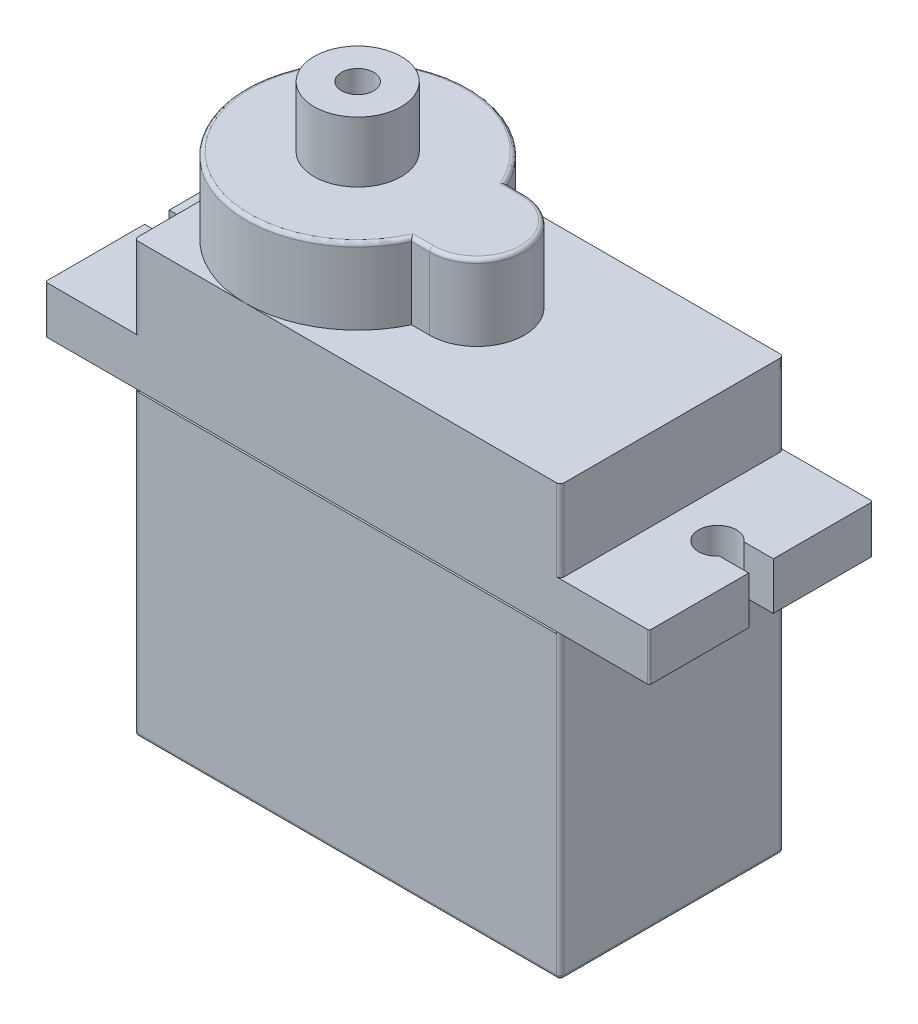
from build123d import *

# Parameters (mm, degrees)
SKETCH1_W           = 22.5
SKETCH1_H           = 22.7
BOSS_EXTRUDE1_DEPTH = 11.8
SKETCH2_W           = 11.8
SKETCH2_H           = 2.5
BOSS_EXTRUDE2_DEPTH = 4.7
SKETCH3_W           = 11.8
SKETCH3_H           = 2.5
BOSS_EXTRUDE3_DEPTH = 4.7
CUT_EXTRUDE1_DEPTH  = 4.7
BOSS_EXTRUDE4_DEPTH = 4
SKETCH6_R           = 2.3
SKETCH6_R_2         = 0.85
BOSS_EXTRUDE5_DEPTH = 3.2
CUT_EXTRUDE2_DEPTH  = 0.1
FILLET1_R           = 0.2
SKETCH8_W           = 22.1
SKETCH8_H           = 0.1
CUT_EXTRUDE3_DEPTH  = 0.1
SKETCH9_W           = 22.1
SKETCH9_H           = 0.1
CUT_EXTRUDE4_DEPTH  = 0.1
FILLET2_R           = 0.1


with BuildPart() as part:
    # Sketch1 → Boss-Extrude1 (new body)
    with BuildSketch(Plane.XY):
        with Locations((11.25, 11.35)):
            Rectangle(SKETCH1_W, SKETCH1_H)
    extrude(amount=BOSS_EXTRUDE1_DEPTH)

    # Sketch2 → Boss-Extrude2 (add)
    with BuildSketch(Plane(origin=(22.5, 0, 0), x_dir=(0, 0, -1), z_dir=(1, 0, 0))):
        with Locations((-5.9, 17.15)):
            Rectangle(SKETCH2_W, SKETCH2_H)
    extrude(amount=BOSS_EXTRUDE2_DEPTH)

    # Sketch3 → Boss-Extrude3 (add)
    with BuildSketch(Plane.ZY):
        with Locations((5.9, 17.15)):
            Rectangle(SKETCH3_W, SKETCH3_H)
    extrude(amount=BOSS_EXTRUDE3_DEPTH)

    # Sketch4 → Cut-Extrude1 (cut)
    with BuildSketch(Plane(origin=(0, 18.4, 0), x_dir=(1, 0, 0), z_dir=(0, 1, 0))):
        with BuildLine():
            Line((27.2, -5.25), (25.659934208, -5.25))
            ThreePointArc((25.659934208, -5.25), (23.9, -5.9), (25.659934208, -6.55))
            Line((25.659934208, -6.55), (27.2, -6.55))
            Line((27.2, -6.55), (27.2, -5.25))
        make_face()
        with BuildLine():
            Line((-4.7, -5.25), (-3.159934208, -5.25))
            ThreePointArc((-3.159934208, -5.25), (-1.4, -5.9), (-3.159934208, -6.55))
            Line((-3.159934208, -6.55), (-4.7, -6.55))
            Line((-4.7, -6.55), (-4.7, -5.25))
        make_face()
    extrude(amount=-CUT_EXTRUDE1_DEPTH, mode=Mode.SUBTRACT)

    # Sketch5 → Boss-Extrude4 (add)
    with BuildSketch(Plane(origin=(0, 22.7, 0), x_dir=(1, 0, 0), z_dir=(0, 1, 0))):
        with BuildLine():
            Line((12.2, -3.4), (11.244155686, -3.4))
            ThreePointArc((11.244155686, -3.4), (0, -5.9), (11.244155686, -8.4))
            Line((11.244155686, -8.4), (12.2, -8.4))
            ThreePointArc((12.2, -8.4), (14.7, -5.9), (12.2, -3.4))
        make_face()
    extrude(amount=BOSS_EXTRUDE4_DEPTH)

    # Sketch6 → Boss-Extrude5 (add)
    with BuildSketch(Plane(origin=(0, 26.7, 0), x_dir=(1, 0, 0), z_dir=(0, 1, 0))):
        with Locations((5.9, -5.9)):
            Circle(SKETCH6_R)
        with Locations((5.9, -5.9)):
            Circle(SKETCH6_R_2, mode=Mode.SUBTRACT)
    extrude(amount=BOSS_EXTRUDE5_DEPTH)

    # Sketch7 → Cut-Extrude2 (cut)
    with BuildSketch(Plane(origin=(0, 0, 0), x_dir=(-1, 0, 0), z_dir=(0, 0, -1))):
        with BuildLine():
            Line((-17.532795325, 8.733140918), (-17.236921928, 8.910524733))
            add(Edge.make_bspline(
                [(-17.236921928, 8.910524733), (-17.209403691, 8.864460348), (-17.15667981, 8.776202764), (-17.068728451, 8.656944723), (-16.97759554, 8.555582566), (-16.882606206, 8.472705959), (-16.784340258, 8.407457072), (-16.682156204, 8.36125484), (-16.576398394, 8.332438865), (-16.504424572, 8.328938779), (-16.468492441, 8.327191399)],
                knots=[0, 0, 0, 0, 0.000160901, 0.00030828, 0.000443778, 0.00056903, 0.000685513, 0.000796284, 0.00090427, 0.001011928, 0.001011928, 0.001011928, 0.001011928], degree=3))
            add(Edge.make_bspline(
                [(-16.468492441, 8.327191399), (-16.43780558, 8.328046072), (-16.376968807, 8.329740462), (-16.287406564, 8.346021264), (-16.200424762, 8.371033393), (-16.117816124, 8.406854324), (-16.04072051, 8.45019281), (-15.973113814, 8.502538988), (-15.914667701, 8.561145193), (-15.866858587, 8.626527848), (-15.830178551, 8.696844997), (-15.801986483, 8.769020948), (-15.786341409, 8.844189516), (-15.783984656, 8.894799979), (-15.782795325, 8.920340438)],
                knots=[0, 0, 0, 0, 9.1978e-05, 0.000182347, 0.000272202, 0.000362975, 0.000451852, 0.000536835, 0.000618639, 0.000699414, 0.000778765, 0.000855983, 0.0009312, 0.001007828, 0.001007828, 0.001007828, 0.001007828], degree=3))
            add(Edge.make_bspline(
                [(-15.782795325, 8.920340438), (-15.784269636, 8.949481287), (-15.787266694, 9.008720376), (-15.812598174, 9.096120029), (-15.852447421, 9.182612599), (-15.889210065, 9.236113865), (-15.908296127, 9.263890117)],
                knots=[0, 0, 0, 0, 8.7281e-05, 0.000177429, 0.000270909, 0.000371844, 0.000371844, 0.000371844, 0.000371844], degree=3))
            add(Edge.make_bspline(
                [(-15.908296127, 9.263890117), (-15.923966741, 9.283936941), (-15.956865235, 9.326022739), (-16.013422748, 9.388667975), (-16.079788862, 9.453286394), (-16.153692417, 9.522345451), (-16.237825506, 9.592633247), (-16.32955302, 9.667501525), (-16.431216879, 9.744103102), (-16.502516376, 9.795475668), (-16.539305742, 9.821983066)],
                knots=[0, 0, 0, 0, 7.6319e-05, 0.000160223, 0.000252933, 0.000354147, 0.000463581, 0.000581729, 0.000709336, 0.000845369, 0.000845369, 0.000845369, 0.000845369], degree=3))
            add(Edge.make_bspline(
                [(-16.539305742, 9.821983066), (-16.576129738, 9.848211653), (-16.646534415, 9.898358716), (-16.744992997, 9.972783), (-16.83303746, 10.040826869), (-16.910276477, 10.103130881), (-16.976676073, 10.159703486), (-17.032759484, 10.210001425), (-17.077098042, 10.255384986), (-17.101753622, 10.284826328), (-17.11282337, 10.298044765)],
                knots=[0, 0, 0, 0, 0.000135623, 0.000259301, 0.000370234, 0.000469439, 0.00055697, 0.000631911, 0.000695377, 0.00074709, 0.00074709, 0.00074709, 0.00074709], degree=3))
            add(Edge.make_bspline(
                [(-17.11282337, 10.298044765), (-17.128295915, 10.318645801), (-17.158724752, 10.359160505), (-17.198890758, 10.422485363), (-17.23302992, 10.487308628), (-17.259792252, 10.553804493), (-17.282328471, 10.621039422), (-17.297486402, 10.689890668), (-17.306977799, 10.760049286), (-17.307949786, 10.807262787), (-17.308436351, 10.830897329)],
                knots=[0, 0, 0, 0, 7.727e-05, 0.000151962, 0.000224716, 0.000296717, 0.00036678, 0.0004372, 0.000507902, 0.000578771, 0.000578771, 0.000578771, 0.000578771], degree=3))
            add(Edge.make_bspline(
                [(-17.308436351, 10.830897329), (-17.307131142, 10.867927103), (-17.304548622, 10.941195167), (-17.282708105, 11.048225997), (-17.248235211, 11.150412415), (-17.199940323, 11.246742748), (-17.13768297, 11.334708729), (-17.065636996, 11.415322216), (-16.97982551, 11.483090798), (-16.885672886, 11.542302857), (-16.782616514, 11.588648782), (-16.674625611, 11.623609762), (-16.561528539, 11.64341902), (-16.484925404, 11.646261785), (-16.446056543, 11.64770422)],
                knots=[0, 0, 0, 0, 0.000110999, 0.000219625, 0.000326272, 0.00043382, 0.000541574, 0.000648775, 0.000756959, 0.000868438, 0.000981703, 0.00109501, 0.001208203, 0.0013248, 0.0013248, 0.0013248, 0.0013248], degree=3))
            add(Edge.make_bspline(
                [(-16.446056543, 11.64770422), (-16.404812443, 11.646281668), (-16.322791091, 11.643452667), (-16.202141876, 11.618855136), (-16.085981159, 11.578154464), (-15.992537894, 11.531965806), (-15.919405133, 11.48583439), (-15.8636324, 11.443814566), (-15.807114949, 11.395439457), (-15.749396895, 11.340580211), (-15.691456235, 11.27873346), (-15.632432783, 11.210322771), (-15.572188514, 11.135766215), (-15.533432654, 11.082541715), (-15.513564556, 11.055256303)],
                knots=[0, 0, 0, 0, 0.000123638, 0.000245877, 0.000367608, 0.000492088, 0.000557638, 0.000626769, 0.000701372, 0.00078072, 0.000865532, 0.000955497, 0.001051745, 0.001152989, 0.001152989, 0.001152989, 0.001152989], degree=3))
            Line((-15.513564556, 11.055256303), (-15.797518883, 10.840011912))
            add(Edge.make_bspline(
                [(-15.797518883, 10.840011912), (-15.814664815, 10.862100602), (-15.847683873, 10.904638256), (-15.897813359, 10.964209571), (-15.945062007, 11.018626051), (-15.991612407, 11.065891179), (-16.035006039, 11.108593312), (-16.077123081, 11.145153069), (-16.117357432, 11.175928664), (-16.168074343, 11.208772224), (-16.231792061, 11.241328728), (-16.311776597, 11.268877806), (-16.395362872, 11.285432868), (-16.452292504, 11.287621755), (-16.481112633, 11.288729861)],
                knots=[0, 0, 0, 0, 8.3877e-05, 0.000161528, 0.000233552, 0.000299993, 0.000360485, 0.000416152, 0.000467195, 0.000512312, 0.000597287, 0.000681099, 0.000765389, 0.000851809, 0.000851809, 0.000851809, 0.000851809], degree=3))
            add(Edge.make_bspline(
                [(-16.481112633, 11.288729861), (-16.517269155, 11.287518161), (-16.586993603, 11.285181512), (-16.685983839, 11.259661526), (-16.775077764, 11.219479666), (-16.851630329, 11.163164688), (-16.915367306, 11.096443695), (-16.961472765, 11.01966484), (-16.989222929, 10.934882437), (-16.992609209, 10.875740781), (-16.994333787, 10.845620886)],
                knots=[0, 0, 0, 0, 0.000108248, 0.000208746, 0.00030443, 0.000399793, 0.000492054, 0.00057947, 0.000666386, 0.000756591, 0.000756591, 0.000756591, 0.000756591], degree=3))
            add(Edge.make_bspline(
                [(-16.994333787, 10.845620886), (-16.99394066, 10.826869408), (-16.993153764, 10.789335788), (-16.982178966, 10.733884366), (-16.968079637, 10.678573027), (-16.945737006, 10.623650444), (-16.914891702, 10.568156085), (-16.874386526, 10.511134348), (-16.823373214, 10.452082639), (-16.784296202, 10.413675265), (-16.763664716, 10.393397329)],
                knots=[0, 0, 0, 0, 5.616e-05, 0.000112411, 0.000169046, 0.000227244, 0.000289691, 0.000359134, 0.000436702, 0.000523463, 0.000523463, 0.000523463, 0.000523463], degree=3))
            add(Edge.make_bspline(
                [(-16.763664716, 10.393397329), (-16.756003344, 10.386560303), (-16.737801677, 10.370317095), (-16.704525751, 10.343724814), (-16.660582953, 10.310922042), (-16.607120752, 10.270334725), (-16.54315339, 10.223253263), (-16.468673834, 10.170279651), (-16.384512301, 10.109694192), (-16.324790385, 10.067336651), (-16.293211992, 10.044939797)],
                knots=[0, 0, 0, 0, 3.0802e-05, 7.3177e-05, 0.000127725, 0.000195314, 0.000274544, 0.000365991, 0.000469501, 0.000585644, 0.000585644, 0.000585644, 0.000585644], degree=3))
            add(Edge.make_bspline(
                [(-16.293211992, 10.044939797), (-16.255226079, 10.017298437), (-16.181671622, 9.963774775), (-16.077014042, 9.883359095), (-15.982120234, 9.804711327), (-15.896657031, 9.72833372), (-15.819780122, 9.654805627), (-15.752342402, 9.583242446), (-15.693656721, 9.514156874), (-15.630477503, 9.425584298), (-15.565919683, 9.316803214), (-15.510478176, 9.183524975), (-15.475519828, 9.049728655), (-15.470948313, 8.959801818), (-15.468692761, 8.915432585)],
                knots=[0, 0, 0, 0, 0.000140932, 0.000272896, 0.000395881, 0.000510584, 0.000616697, 0.000714904, 0.000805482, 0.000888372, 0.001041088, 0.001183793, 0.001320341, 0.001453327, 0.001453327, 0.001453327, 0.001453327], degree=3))
            add(Edge.make_bspline(
                [(-15.468692761, 8.915432585), (-15.469349899, 8.88405422), (-15.470651414, 8.821906836), (-15.485612328, 8.73065176), (-15.507531993, 8.64202089), (-15.540569227, 8.557109777), (-15.580892386, 8.474365015), (-15.632058633, 8.395957114), (-15.691366318, 8.320150716), (-15.759400083, 8.248967224), (-15.833845985, 8.183621028), (-15.91252968, 8.125491967), (-15.995579953, 8.077023644), (-16.08254627, 8.037472801), (-16.173448606, 8.006539284), (-16.26825639, 7.984126415), (-16.367125901, 7.970370704), (-16.434326383, 7.968942942), (-16.468492441, 7.96821704)],
                knots=[0, 0, 0, 0, 9.4044e-05, 0.000186263, 0.000276729, 0.000367488, 0.000459046, 0.000552398, 0.000647774, 0.000747454, 0.000847311, 0.000944634, 0.001040472, 0.001135227, 0.001230788, 0.001328063, 0.00142712, 0.00152957, 0.00152957, 0.00152957, 0.00152957], degree=3))
            add(Edge.make_bspline(
                [(-16.468492441, 7.96821704), (-16.494927784, 7.968728222), (-16.547465544, 7.969744147), (-16.625175026, 7.978725428), (-16.701314615, 7.991432531), (-16.774928897, 8.011606601), (-16.846966308, 8.036083578), (-16.917113543, 8.066221911), (-16.985404597, 8.102339112), (-17.05222218, 8.143634137), (-17.117396354, 8.191691881), (-17.180315822, 8.247665378), (-17.243045008, 8.310010883), (-17.303732404, 8.380421446), (-17.363605548, 8.457759529), (-17.421483958, 8.542748713), (-17.478565676, 8.634926066), (-17.514381143, 8.699791152), (-17.532795325, 8.733140918)],
                knots=[0, 0, 0, 0, 7.9276e-05, 0.000157554, 0.000234438, 0.000310629, 0.000386236, 0.000462555, 0.000539392, 0.000617798, 0.000698008, 0.000781971, 0.000870217, 0.00096315, 0.001060616, 0.001163492, 0.001271478, 0.00138575, 0.00138575, 0.00138575, 0.00138575], degree=3))
        make_face()
        with BuildLine():
            Line((-11.475103018, 10.960604861), (-11.744333787, 10.705396527))
            add(Edge.make_bspline(
                [(-11.744333787, 10.705396527), (-11.793052675, 10.75122739), (-11.889328721, 10.841796253), (-12.046288964, 10.959307248), (-12.210052598, 11.059973349), (-12.379765095, 11.141879585), (-12.551223649, 11.207232346), (-12.722152425, 11.253760486), (-12.890798127, 11.283433023), (-13.002965345, 11.286981393), (-13.05823603, 11.288729861)],
                knots=[0, 0, 0, 0, 0.000200536, 0.000396289, 0.000586999, 0.000776397, 0.000960787, 0.001136655, 0.001307246, 0.001472961, 0.001472961, 0.001472961, 0.001472961], degree=3))
            add(Edge.make_bspline(
                [(-13.05823603, 11.288729861), (-13.09215073, 11.288316255), (-13.159892171, 11.287490116), (-13.260514115, 11.2769459), (-13.360080752, 11.261781036), (-13.458404127, 11.239839159), (-13.555675413, 11.212030099), (-13.651556305, 11.177244636), (-13.74622566, 11.136689392), (-13.838791741, 11.089826918), (-13.928532245, 11.038347072), (-14.01328908, 10.981298531), (-14.093602479, 10.920509741), (-14.167962905, 10.854458762), (-14.236798091, 10.783743896), (-14.301746463, 10.70968059), (-14.360523759, 10.630245372), (-14.413614924, 10.546899746), (-14.460976542, 10.461107556), (-14.502785196, 10.373694567), (-14.537882284, 10.284950712), (-14.565651739, 10.194764635), (-14.588562393, 10.103834045), (-14.60468, 10.011529324), (-14.613766723, 9.917751639), (-14.615338503, 9.85495438), (-14.616128659, 9.823385309)],
                knots=[0, 0, 0, 0, 0.000101701, 0.000203139, 0.000303193, 0.000403728, 0.000505139, 0.000606491, 0.000709509, 0.000813922, 0.000917583, 0.001019673, 0.001120217, 0.001219549, 0.001317716, 0.001416124, 0.001514842, 0.00161384, 0.001712379, 0.001808658, 0.001904353, 0.001998376, 0.002091562, 0.002185504, 0.002279198, 0.002373914, 0.002373914, 0.002373914, 0.002373914], degree=3))
            add(Edge.make_bspline(
                [(-14.616128659, 9.823385309), (-14.61537294, 9.791114492), (-14.613863567, 9.726660979), (-14.604203248, 9.630466906), (-14.586275007, 9.535701504), (-14.562307299, 9.442053371), (-14.532326483, 9.349362123), (-14.494953817, 9.258029613), (-14.450688216, 9.168059222), (-14.399451664, 9.080261605), (-14.343265461, 8.994738581), (-14.28032238, 8.91417906), (-14.213461796, 8.837510282), (-14.140247897, 8.766434519), (-14.063028354, 8.699050622), (-13.979496078, 8.6372151), (-13.891293618, 8.579736877), (-13.798286406, 8.527340358), (-13.701483623, 8.480531822), (-13.60222687, 8.438907926), (-13.500199055, 8.404628589), (-13.395936365, 8.376690485), (-13.289563093, 8.353790187), (-13.180539291, 8.339057707), (-13.069666582, 8.328366876), (-12.99492795, 8.327585206), (-12.957274492, 8.327191399)],
                knots=[0, 0, 0, 0, 9.6818e-05, 0.000193372, 0.000289633, 0.000385881, 0.000483216, 0.000581645, 0.00068167, 0.000783767, 0.00088644, 0.000988395, 0.001090231, 0.001191373, 0.001294266, 0.001397472, 0.001502873, 0.001609927, 0.001717482, 0.001825293, 0.001932604, 0.002040093, 0.002149, 0.002258763, 0.002369974, 0.002482889, 0.002482889, 0.002482889, 0.002482889], degree=3))
            add(Edge.make_bspline(
                [(-12.957274492, 8.327191399), (-12.911896145, 8.328139975), (-12.822788387, 8.330002659), (-12.691801945, 8.344502949), (-12.565998874, 8.367149742), (-12.445732671, 8.400315639), (-12.33086365, 8.442619314), (-12.220970709, 8.4936147), (-12.11691905, 8.555257759), (-12.018395877, 8.624831627), (-11.927638691, 8.702346459), (-11.845784567, 8.785990914), (-11.774139078, 8.875358981), (-11.711634378, 8.969924296), (-11.659925724, 9.070469601), (-11.617482929, 9.176502164), (-11.584949637, 9.288069676), (-11.571594663, 9.365161307), (-11.564846607, 9.404114476)],
                knots=[0, 0, 0, 0, 0.000136106, 0.000267267, 0.000394882, 0.00051922, 0.000641, 0.000761758, 0.000882124, 0.001003321, 0.001123172, 0.001239687, 0.001353892, 0.00146629, 0.00157918, 0.001692449, 0.001808499, 0.001927028, 0.001927028, 0.001927028, 0.001927028], degree=3))
            Line((-11.564846607, 9.404114476), (-12.731513274, 9.404114476))
            Line((-12.731513274, 9.404114476), (-12.731513274, 9.763088835))
            Line((-12.731513274, 9.763088835), (-11.250744043, 9.763088835))
            add(Edge.make_bspline(
                [(-11.250744043, 9.763088835), (-11.252449892, 9.696181346), (-11.255788545, 9.565231304), (-11.279207461, 9.374261034), (-11.317023973, 9.19388934), (-11.368684285, 9.023926269), (-11.435559565, 8.864612676), (-11.516932094, 8.71578681), (-11.614104215, 8.578410129), (-11.723614656, 8.451361125), (-11.846514614, 8.338031913), (-11.979483234, 8.238425975), (-12.122740202, 8.15452336), (-12.27615001, 8.086262697), (-12.439210443, 8.032988703), (-12.612298823, 7.995217126), (-12.795180424, 7.972587162), (-12.920517101, 7.969695783), (-12.984618242, 7.96821704)],
                knots=[0, 0, 0, 0, 0.000200697, 0.000392801, 0.000576238, 0.000752994, 0.000924878, 0.001093697, 0.001260784, 0.001428776, 0.001595974, 0.001761299, 0.001926279, 0.002092931, 0.002264096, 0.002439994, 0.002623661, 0.002815923, 0.002815923, 0.002815923, 0.002815923], degree=3))
            add(Edge.make_bspline(
                [(-12.984618242, 7.96821704), (-13.024128377, 7.968786161), (-13.102055098, 7.969908652), (-13.217146026, 7.977885999), (-13.329063647, 7.990166576), (-13.437791656, 8.008711699), (-13.543729998, 8.031426353), (-13.646349583, 8.060513072), (-13.746041325, 8.094181771), (-13.84295931, 8.132477445), (-13.936223857, 8.176849102), (-14.026250374, 8.226158741), (-14.1135365, 8.280152102), (-14.197487665, 8.339762948), (-14.278541286, 8.404545408), (-14.35617473, 8.474629327), (-14.430822608, 8.549800446), (-14.477583072, 8.603179456), (-14.501144684, 8.630076015)],
                knots=[0, 0, 0, 0, 0.000118523, 0.000233765, 0.000345956, 0.000456148, 0.000564516, 0.000670839, 0.000775933, 0.000880089, 0.000983271, 0.001085557, 0.001187895, 0.001290998, 0.001394253, 0.001499002, 0.001604602, 0.001711853, 0.001711853, 0.001711853, 0.001711853], degree=3))
            add(Edge.make_bspline(
                [(-14.501144684, 8.630076015), (-14.535330616, 8.672746668), (-14.603135029, 8.757379685), (-14.690413185, 8.892979629), (-14.764814588, 9.033381489), (-14.82518241, 9.178976118), (-14.872320497, 9.329627331), (-14.906126749, 9.485142622), (-14.925934039, 9.645722252), (-14.928787576, 9.754387517), (-14.930231223, 9.809362874)],
                knots=[0, 0, 0, 0, 0.00016394, 0.000325158, 0.000482912, 0.000640071, 0.000797293, 0.000955853, 0.00111691, 0.001281823, 0.001281823, 0.001281823, 0.001281823], degree=3))
            add(Edge.make_bspline(
                [(-14.930231223, 9.809362874), (-14.929698985, 9.850529126), (-14.928641273, 9.932338434), (-14.915815757, 10.053795741), (-14.897414339, 10.173096433), (-14.870367284, 10.29014299), (-14.836271019, 10.405013581), (-14.793717533, 10.517761545), (-14.744172637, 10.628453417), (-14.686587141, 10.736327285), (-14.622502682, 10.839951698), (-14.552952461, 10.938909501), (-14.476948861, 11.031398566), (-14.395733062, 11.118590214), (-14.308336071, 11.199389061), (-14.215576648, 11.274543172), (-14.117383305, 11.344153358), (-14.013447125, 11.407123192), (-13.90531944, 11.463686813), (-13.793259439, 11.513276025), (-13.677301328, 11.55425934), (-13.55831385, 11.58903312), (-13.43539635, 11.61474826), (-13.309440813, 11.633397006), (-13.179790701, 11.646157605), (-13.092154672, 11.647183861), (-13.047719203, 11.64770422)],
                knots=[0, 0, 0, 0, 0.000123447, 0.000245326, 0.00036601, 0.000485407, 0.000605413, 0.000725221, 0.000846669, 0.000968994, 0.001091771, 0.00121199, 0.001331568, 0.001450618, 0.001569191, 0.001688326, 0.001808545, 0.001929991, 0.002052609, 0.002174413, 0.002297271, 0.002421315, 0.002546037, 0.002673651, 0.002803207, 0.002936466, 0.002936466, 0.002936466, 0.002936466], degree=3))
            add(Edge.make_bspline(
                [(-13.047719203, 11.64770422), (-13.01148096, 11.647124728), (-12.939624781, 11.645975664), (-12.832699049, 11.638011016), (-12.727426034, 11.625387135), (-12.623649644, 11.608160348), (-12.521723278, 11.584696658), (-12.421356573, 11.556618373), (-12.322404036, 11.52392655), (-12.225175787, 11.484937704), (-12.129018071, 11.440684079), (-12.033396231, 11.390870657), (-11.938636985, 11.334645652), (-11.844576003, 11.271842117), (-11.750620145, 11.203538699), (-11.658255503, 11.127781875), (-11.565252559, 11.047559119), (-11.505450745, 10.989876935), (-11.475103018, 10.960604861)],
                knots=[0, 0, 0, 0, 0.00010871, 0.000215559, 0.000321482, 0.000426718, 0.00053098, 0.000635089, 0.000739295, 0.000843451, 0.000949174, 0.001056739, 0.001166761, 0.001279546, 0.001395941, 0.001515076, 0.00163782, 0.001764288, 0.001764288, 0.001764288, 0.001764288], degree=3))
        make_face()
        with BuildLine():
            Line((-8.73792353, 7.96821704), (-8.988925133, 8.142796367))
            Line((-8.988925133, 8.142796367), (-8.015768082, 9.565372489))
            add(Edge.make_bspline(
                [(-8.015768082, 9.565372489), (-8.077858817, 9.557779426), (-8.200118937, 9.542828261), (-8.323256039, 9.540081606), (-8.383857024, 9.538729861)],
                knots=[0, 0, 0, 0, 0.000187529, 0.000369255, 0.000369255, 0.000369255, 0.000369255], degree=3))
            add(Edge.make_bspline(
                [(-8.383857024, 9.538729861), (-8.420599072, 9.539670937), (-8.492720499, 9.541518188), (-8.598752151, 9.556159996), (-8.700637712, 9.578710124), (-8.798107068, 9.612358879), (-8.891526573, 9.654177088), (-8.980692286, 9.706034102), (-9.065484176, 9.767040393), (-9.144991586, 9.836873385), (-9.217303325, 9.913551437), (-9.281726623, 9.99470708), (-9.335267755, 10.081283051), (-9.37974434, 10.17151327), (-9.413474794, 10.266694621), (-9.438037332, 10.365744021), (-9.453159686, 10.469355663), (-9.454958781, 10.539880794), (-9.455872248, 10.575688995)],
                knots=[0, 0, 0, 0, 0.000110185, 0.000216284, 0.000320547, 0.000422759, 0.000525058, 0.000627155, 0.000731643, 0.000837964, 0.0009441, 0.00104747, 0.001148247, 0.001248901, 0.001348697, 0.001450555, 0.001554666, 0.00166205, 0.00166205, 0.00166205, 0.00166205], degree=3))
            add(Edge.make_bspline(
                [(-9.455872248, 10.575688995), (-9.454137814, 10.624657648), (-9.45073347, 10.72077318), (-9.423334953, 10.861206949), (-9.378274613, 10.993993492), (-9.315446237, 11.118783686), (-9.236311515, 11.233782425), (-9.141202925, 11.337391035), (-9.030698961, 11.428135888), (-8.907316942, 11.506139966), (-8.773963921, 11.568874963), (-8.634295263, 11.615114264), (-8.489381143, 11.642313011), (-8.391213473, 11.645898873), (-8.341789716, 11.64770422)],
                knots=[0, 0, 0, 0, 0.000146818, 0.000288173, 0.000427413, 0.000566316, 0.000705952, 0.000844895, 0.000986821, 0.001133677, 0.001281714, 0.001427825, 0.001574003, 0.00172222, 0.00172222, 0.00172222, 0.00172222], degree=3))
            add(Edge.make_bspline(
                [(-8.341789716, 11.64770422), (-8.293301297, 11.645874057), (-8.19749275, 11.642257827), (-8.056603743, 11.615773858), (-7.921662726, 11.571137185), (-7.79341774, 11.509452621), (-7.674678327, 11.432131714), (-7.567902516, 11.33999719), (-7.475526977, 11.232991663), (-7.397703096, 11.113703173), (-7.335233056, 10.985536191), (-7.290160773, 10.851752269), (-7.262415134, 10.713313548), (-7.258918807, 10.619519074), (-7.2571543, 10.572183386)],
                knots=[0, 0, 0, 0, 0.000145418, 0.000287333, 0.000428343, 0.000570713, 0.000713061, 0.00085223, 0.000992387, 0.001135706, 0.001278381, 0.001418948, 0.001558239, 0.001700158, 0.001700158, 0.001700158, 0.001700158], degree=3))
            add(Edge.make_bspline(
                [(-7.2571543, 10.572183386), (-7.258332709, 10.535439619), (-7.260722816, 10.460914079), (-7.277459123, 10.347683736), (-7.305879309, 10.232232506), (-7.338131007, 10.13451091), (-7.369263175, 10.053802461), (-7.398564307, 9.990050881), (-7.43107646, 9.922949617), (-7.468995226, 9.853202279), (-7.509757522, 9.779919745), (-7.555816799, 9.703837029), (-7.606122371, 9.624852036), (-7.64195209, 9.571604948), (-7.660299332, 9.544338835)],
                knots=[0, 0, 0, 0, 0.000110219, 0.000223552, 0.000342587, 0.000466527, 0.000532018, 0.000601997, 0.000676938, 0.00075567, 0.000840114, 0.000928491, 0.001022434, 0.001121023, 0.001121023, 0.001121023, 0.001121023], degree=3))
            Line((-7.660299332, 9.544338835), (-8.73792353, 7.96821704))
        make_face()
        with BuildLine():
            add(Edge.make_bspline(
                [(-8.325663915, 9.89770422), (-8.297829901, 9.898464603), (-8.243646538, 9.899944812), (-8.164269239, 9.908954054), (-8.089345035, 9.92492804), (-8.018673786, 9.947847752), (-7.951546884, 9.975504421), (-7.889030556, 10.010716407), (-7.831072481, 10.052733042), (-7.777284554, 10.099943058), (-7.729520554, 10.152393641), (-7.686977523, 10.207290748), (-7.650816956, 10.264875358), (-7.622253679, 10.32586862), (-7.598769103, 10.388785829), (-7.582551091, 10.454640184), (-7.573566758, 10.523088585), (-7.572035183, 10.569587243), (-7.571256864, 10.59321704)],
                knots=[0, 0, 0, 0, 8.3507e-05, 0.00016256, 0.000239294, 0.000312908, 0.000385178, 0.000456751, 0.000527578, 0.000599603, 0.000671055, 0.000740051, 0.000807755, 0.000874553, 0.000941763, 0.001008931, 0.001077548, 0.001148448, 0.001148448, 0.001148448, 0.001148448], degree=3))
            add(Edge.make_bspline(
                [(-7.571256864, 10.59321704), (-7.571926533, 10.616856705), (-7.573246198, 10.663441565), (-7.583833498, 10.731991305), (-7.602458721, 10.797684566), (-7.627449206, 10.860880996), (-7.660369444, 10.921061368), (-7.699872929, 10.97898124), (-7.746805379, 11.034273367), (-7.800807945, 11.085637351), (-7.859042498, 11.13298525), (-7.921102998, 11.174771326), (-7.986477914, 11.209792523), (-8.054768404, 11.238691493), (-8.126116753, 11.261243268), (-8.200480741, 11.277460633), (-8.278236147, 11.286432387), (-8.331017433, 11.287954282), (-8.357915518, 11.288729861)],
                knots=[0, 0, 0, 0, 7.09e-05, 0.000139717, 0.000207422, 0.000275384, 0.000343146, 0.000412766, 0.000485392, 0.000560268, 0.000636041, 0.000710323, 0.000784354, 0.000858188, 0.000932471, 0.001008519, 0.001086179, 0.001166885, 0.001166885, 0.001166885, 0.001166885], degree=3))
            add(Edge.make_bspline(
                [(-8.357915518, 11.288729861), (-8.384579671, 11.287953029), (-8.43689452, 11.286428892), (-8.51395868, 11.277477687), (-8.587819848, 11.261134202), (-8.658961468, 11.238701938), (-8.727249928, 11.209790367), (-8.792621761, 11.174769491), (-8.854696778, 11.132994869), (-8.912875499, 11.085600097), (-8.966973421, 11.03451245), (-9.01309895, 10.978739021), (-9.052692842, 10.921091497), (-9.085567845, 10.860872989), (-9.110570362, 10.797686703), (-9.129192364, 10.731990726), (-9.139780529, 10.663441716), (-9.141100075, 10.616856756), (-9.141769684, 10.59321704)],
                knots=[0, 0, 0, 0, 8.0005e-05, 0.000156969, 0.000232332, 0.000306614, 0.000380449, 0.000454479, 0.000528762, 0.000604535, 0.000679411, 0.000751586, 0.000821205, 0.000888968, 0.00095693, 0.001024634, 0.001093451, 0.001164351, 0.001164351, 0.001164351, 0.001164351], degree=3))
            add(Edge.make_bspline(
                [(-9.141769684, 10.59321704), (-9.141163758, 10.569568841), (-9.139968761, 10.522930265), (-9.128440971, 10.454403872), (-9.109162691, 10.388715678), (-9.083343301, 10.325226971), (-9.049341711, 10.264555113), (-9.007617863, 10.206987751), (-8.958712317, 10.151872301), (-8.903278829, 10.100065089), (-8.842610668, 10.052512914), (-8.777813922, 10.010982532), (-8.710004085, 9.975910087), (-8.638942454, 9.947768703), (-8.565155654, 9.92515704), (-8.487980523, 9.908983495), (-8.407672286, 9.900031228), (-8.353262304, 9.898487331), (-8.325663915, 9.89770422)],
                knots=[0, 0, 0, 0, 7.09e-05, 0.000139828, 0.000207725, 0.00027595, 0.000345002, 0.000415829, 0.000488844, 0.000565728, 0.000643147, 0.000719775, 0.000796287, 0.0008718, 0.000948761, 0.001027552, 0.001107998, 0.001190805, 0.001190805, 0.001190805, 0.001190805], degree=3))
        make_face(mode=Mode.SUBTRACT)
        with BuildLine():
            add(Edge.make_bspline(
                [(-6.808436351, 9.806558386), (-6.808108333, 9.862655774), (-6.807471153, 9.971625758), (-6.800382732, 10.1304104), (-6.78860739, 10.279370689), (-6.772470017, 10.418513755), (-6.752832036, 10.54787552), (-6.72661655, 10.667110277), (-6.696803747, 10.776769884), (-6.662251301, 10.877211932), (-6.623263512, 10.969789635), (-6.580829252, 11.056214837), (-6.533264457, 11.136356769), (-6.483287544, 11.211494559), (-6.428875473, 11.280398254), (-6.371576682, 11.344040917), (-6.309154806, 11.400951667), (-6.243731798, 11.452797969), (-6.174715333, 11.498247441), (-6.104072667, 11.53828018), (-6.031317561, 11.572480047), (-5.956251378, 11.599370483), (-5.879548821, 11.62158133), (-5.800941754, 11.636770277), (-5.72030039, 11.646327186), (-5.665868955, 11.647240853), (-5.638264075, 11.64770422)],
                knots=[0, 0, 0, 0, 0.000168282, 0.000326891, 0.000476705, 0.00061646, 0.000747059, 0.00086904, 0.000982494, 0.001087814, 0.001187428, 0.001283689, 0.001376399, 0.001466822, 0.001554203, 0.001639568, 0.001723424, 0.001807301, 0.001889751, 0.001971063, 0.002050735, 0.002130583, 0.002210036, 0.002290062, 0.002370508, 0.002453288, 0.002453288, 0.002453288, 0.002453288], degree=3))
            add(Edge.make_bspline(
                [(-5.638264075, 11.64770422), (-5.610428597, 11.647216405), (-5.555072588, 11.646246294), (-5.473232213, 11.636922351), (-5.393282531, 11.621451228), (-5.315564392, 11.599530253), (-5.239439406, 11.572334577), (-5.165502998, 11.53824746), (-5.093295916, 11.498568592), (-5.023965629, 11.451944715), (-4.956751014, 11.399962439), (-4.893303051, 11.34119977), (-4.833615965, 11.276250051), (-4.776940659, 11.205808187), (-4.724885062, 11.128523102), (-4.67531163, 11.045738992), (-4.630939594, 10.956008127), (-4.588204919, 10.86082766), (-4.551317932, 10.757564001), (-4.518051687, 10.64679924), (-4.491172718, 10.527225053), (-4.468783446, 10.399468808), (-4.45143855, 10.263061325), (-4.438805908, 10.118295009), (-4.432132823, 9.965074619), (-4.430876122, 9.860316769), (-4.430231223, 9.806558386)],
                knots=[0, 0, 0, 0, 8.3481e-05, 0.000166017, 0.000246731, 0.000327534, 0.000408041, 0.000488986, 0.000571522, 0.000654944, 0.000739373, 0.000826202, 0.000914021, 0.001003809, 0.001097153, 0.001193347, 0.001293057, 0.001397277, 0.001506176, 0.001621751, 0.001744038, 0.001873599, 0.002010742, 0.002156422, 0.002309427, 0.002470709, 0.002470709, 0.002470709, 0.002470709], degree=3))
            add(Edge.make_bspline(
                [(-4.430231223, 9.806558386), (-4.430882807, 9.753034478), (-4.432152393, 9.648745327), (-4.4387311, 9.496214351), (-4.451689731, 9.352216308), (-4.467899719, 9.216405845), (-4.490350682, 9.089348227), (-4.517955849, 8.970603778), (-4.548606171, 8.859659707), (-4.586440966, 8.757424895), (-4.627851676, 8.662473172), (-4.672906872, 8.573806024), (-4.721176698, 8.490639731), (-4.773765443, 8.413639984), (-4.829818856, 8.342261327), (-4.890536645, 8.277763704), (-4.95420723, 8.218593032), (-5.021619646, 8.165941405), (-5.092031197, 8.1198566), (-5.163990274, 8.07864275), (-5.238773658, 8.045410055), (-5.31468661, 8.016875014), (-5.392814976, 7.995074562), (-5.473061367, 7.980000706), (-5.555017603, 7.969428858), (-5.610419168, 7.968622378), (-5.638264075, 7.96821704)],
                knots=[0, 0, 0, 0, 0.000160581, 0.000312886, 0.000457868, 0.000594226, 0.000723097, 0.000844701, 0.000959884, 0.001068125, 0.001171421, 0.001270505, 0.001366343, 0.001459687, 0.001550023, 0.00163832, 0.001725149, 0.001810562, 0.001894568, 0.001977446, 0.00205903, 0.002139777, 0.00222058, 0.002301983, 0.002384599, 0.00246808, 0.00246808, 0.00246808, 0.00246808], degree=3))
            add(Edge.make_bspline(
                [(-5.638264075, 7.96821704), (-5.665868189, 7.968683396), (-5.720298114, 7.969602958), (-5.800950539, 7.979116689), (-5.879232983, 7.994412192), (-5.955531737, 8.015828796), (-6.030238252, 8.042043633), (-6.102334539, 8.076197316), (-6.172622222, 8.115531385), (-6.240913778, 8.160326807), (-6.305925939, 8.21164849), (-6.368024545, 8.268412779), (-6.425649564, 8.33203619), (-6.479283659, 8.401514113), (-6.530257748, 8.476207355), (-6.577147121, 8.557135728), (-6.620517975, 8.643978339), (-6.660161466, 8.737296249), (-6.695310129, 8.838451177), (-6.726357837, 8.948600356), (-6.750871995, 9.068715992), (-6.77185495, 9.197833359), (-6.788779333, 9.336507289), (-6.800333659, 9.484813068), (-6.807474974, 9.642658277), (-6.808110044, 9.750928051), (-6.808436351, 9.806558386)],
                knots=[0, 0, 0, 0, 8.278e-05, 0.000163226, 0.000243252, 0.00032184, 0.00040079, 0.000480463, 0.00056082, 0.000642298, 0.000725191, 0.000809047, 0.000894412, 0.000982346, 0.001072188, 0.001165503, 0.001262704, 0.001363236, 0.001469448, 0.001583766, 0.001706286, 0.001836995, 0.001976138, 0.002125253, 0.002283161, 0.002450041, 0.002450041, 0.002450041, 0.002450041], degree=3))
        make_face()
        with BuildLine():
            add(Edge.make_bspline(
                [(-6.494333787, 9.80796063), (-6.49421434, 9.761211931), (-6.493982516, 9.670481886), (-6.487926316, 9.538638625), (-6.479676084, 9.415668297), (-6.469034787, 9.30141476), (-6.453231838, 9.196264748), (-6.43552505, 9.099495065), (-6.413976961, 9.011617827), (-6.388481943, 8.932030017), (-6.359442846, 8.859380948), (-6.327736982, 8.791779733), (-6.293676259, 8.728427797), (-6.255557109, 8.669894188), (-6.214042046, 8.615988024), (-6.170068786, 8.565755192), (-6.121996202, 8.520958211), (-6.05549246, 8.467231356), (-5.967695985, 8.411712222), (-5.85707553, 8.363366132), (-5.743407079, 8.332983676), (-5.666255829, 8.32911992), (-5.627747248, 8.327191399)],
                knots=[0, 0, 0, 0, 0.000140231, 0.000272162, 0.000395845, 0.00050998, 0.000616273, 0.00071473, 0.000805025, 0.000887508, 0.000965234, 0.00103957, 0.001111417, 0.001180842, 0.001248855, 0.001315406, 0.001380877, 0.0014457, 0.001571746, 0.00169106, 0.001806864, 0.001922266, 0.001922266, 0.001922266, 0.001922266], degree=3))
            add(Edge.make_bspline(
                [(-5.627747248, 8.327191399), (-5.588989577, 8.32878918), (-5.511554254, 8.331981443), (-5.398420458, 8.36278018), (-5.288590188, 8.40924972), (-5.202518248, 8.464197225), (-5.137035705, 8.516525555), (-5.090118714, 8.561140203), (-5.047056666, 8.61109607), (-5.006214591, 8.664995366), (-4.968755515, 8.72386785), (-4.934692378, 8.787430425), (-4.90360903, 8.855859603), (-4.885899984, 8.903629343), (-4.876845806, 8.928052777)],
                knots=[0, 0, 0, 0, 0.000116044, 0.000231848, 0.000349318, 0.000472837, 0.000536674, 0.000600645, 0.000666733, 0.000734322, 0.000803367, 0.000875831, 0.000950509, 0.001028633, 0.001028633, 0.001028633, 0.001028633], degree=3))
            add(Edge.make_bspline(
                [(-4.876845806, 8.928052777), (-4.866294038, 8.959282517), (-4.844869424, 9.022692281), (-4.81725765, 9.121055933), (-4.795512251, 9.224258697), (-4.775948885, 9.331683814), (-4.762595829, 9.444123515), (-4.751848016, 9.561229899), (-4.745517329, 9.683091261), (-4.744732578, 9.765886252), (-4.744333787, 9.80796063)],
                knots=[0, 0, 0, 0, 9.8886e-05, 0.00020078, 0.000306259, 0.000415188, 0.00052824, 0.000645799, 0.000767957, 0.000894177, 0.000894177, 0.000894177, 0.000894177], degree=3))
            add(Edge.make_bspline(
                [(-4.744333787, 9.80796063), (-4.744883976, 9.850028202), (-4.745960264, 9.932321367), (-4.750074252, 10.052839548), (-4.760697826, 10.167307309), (-4.772496945, 10.276217781), (-4.789894166, 10.378968084), (-4.808651973, 10.476418389), (-4.833853185, 10.567361414), (-4.86077296, 10.653220996), (-4.891583356, 10.73302165), (-4.92549909, 10.807135437), (-4.961720849, 10.875920162), (-5.001063089, 10.939187103), (-5.043058772, 10.997219646), (-5.088816321, 11.048854241), (-5.136520694, 11.095691209), (-5.20333788, 11.149153778), (-5.29081217, 11.203665473), (-5.399657817, 11.253831233), (-5.512928461, 11.282639526), (-5.589501915, 11.286701213), (-5.627747248, 11.288729861)],
                knots=[0, 0, 0, 0, 0.000126219, 0.000246912, 0.000361616, 0.00047102, 0.00057545, 0.000674176, 0.000768567, 0.000858368, 0.000944043, 0.001024988, 0.001102772, 0.001177091, 0.00124833, 0.001317386, 0.001383826, 0.001448649, 0.001573728, 0.001692043, 0.001806995, 0.001921698, 0.001921698, 0.001921698, 0.001921698], degree=3))
            add(Edge.make_bspline(
                [(-5.627747248, 11.288729861), (-5.66645784, 11.286698414), (-5.743949546, 11.28263182), (-5.858397501, 11.253938566), (-5.968101852, 11.2039256), (-6.055344827, 11.148973228), (-6.122208614, 11.096634917), (-6.169291307, 11.051248462), (-6.213437479, 11.001602208), (-6.254105179, 10.947200293), (-6.292194463, 10.888734926), (-6.327175475, 10.825746161), (-6.358692805, 10.757914797), (-6.387777341, 10.685298362), (-6.413350129, 10.605717417), (-6.434444092, 10.517948424), (-6.453931145, 10.421486532), (-6.467726414, 10.315767024), (-6.47999017, 10.20148487), (-6.487871518, 10.078207552), (-6.494002775, 9.946143172), (-6.49422124, 9.854944013), (-6.494333787, 9.80796063)],
                knots=[0, 0, 0, 0, 0.000116101, 0.000232413, 0.000351368, 0.000476447, 0.000540832, 0.000605795, 0.000672346, 0.000739935, 0.00080936, 0.000881545, 0.00095588, 0.001033607, 0.001116089, 0.001206384, 0.001304286, 0.001411174, 0.001526077, 0.001649061, 0.001781692, 0.001922624, 0.001922624, 0.001922624, 0.001922624], degree=3))
        make_face(mode=Mode.SUBTRACT)
    extrude(amount=-CUT_EXTRUDE2_DEPTH, mode=Mode.SUBTRACT)

    # Fillet1
    fillet1_edges = [part.edges().sort_by_distance(p)[0] for p in [
        (22.5, 7.95, 11.8),
        (22.5, 20.55, 0),
        (22.5, 20.55, 11.8),
        (0, 7.95, 0),
        (0, 7.95, 11.8),
        (0, 20.55, 11.8),
        (22.5, 7.95, 0),
        (11.25, 0, 0),
        (0, 20.55, 0),
        (11.25, 0, 11.8),
        (22.5, 0, 5.9),
        (0, 0, 5.9),
        (0, 26.7, 5.9),
        (11.722077843, 26.7, 8.4),
        (14.7, 26.7, 5.9),
        (11.722077843, 26.7, 3.4),
    ]]
    fillet(fillet1_edges, radius=FILLET1_R)

    # Sketch8 → Cut-Extrude3 (cut)
    with BuildSketch(Plane(origin=(0, 0, 0), x_dir=(-1, 0, 0), z_dir=(0, 0, -1))):
        with Locations((-11.25, 15.85)):
            Rectangle(SKETCH8_W, SKETCH8_H)
    extrude(amount=-CUT_EXTRUDE3_DEPTH, mode=Mode.SUBTRACT)

    # Sketch9 → Cut-Extrude4 (cut)
    with BuildSketch(Plane.XY.offset(11.8)):
        with Locations((11.25, 15.85)):
            Rectangle(SKETCH9_W, SKETCH9_H)
    extrude(amount=-CUT_EXTRUDE4_DEPTH, mode=Mode.SUBTRACT)

    # Fillet2
    fillet2_edges = [part.edges().sort_by_distance(p)[0] for p in [
        (27.2, 17.15, 11.8),
        (27.2, 17.15, 0),
        (-4.7, 17.15, 0),
        (-4.7, 17.15, 11.8),
    ]]
    fillet(fillet2_edges, radius=FILLET2_R)


solid = part.part
